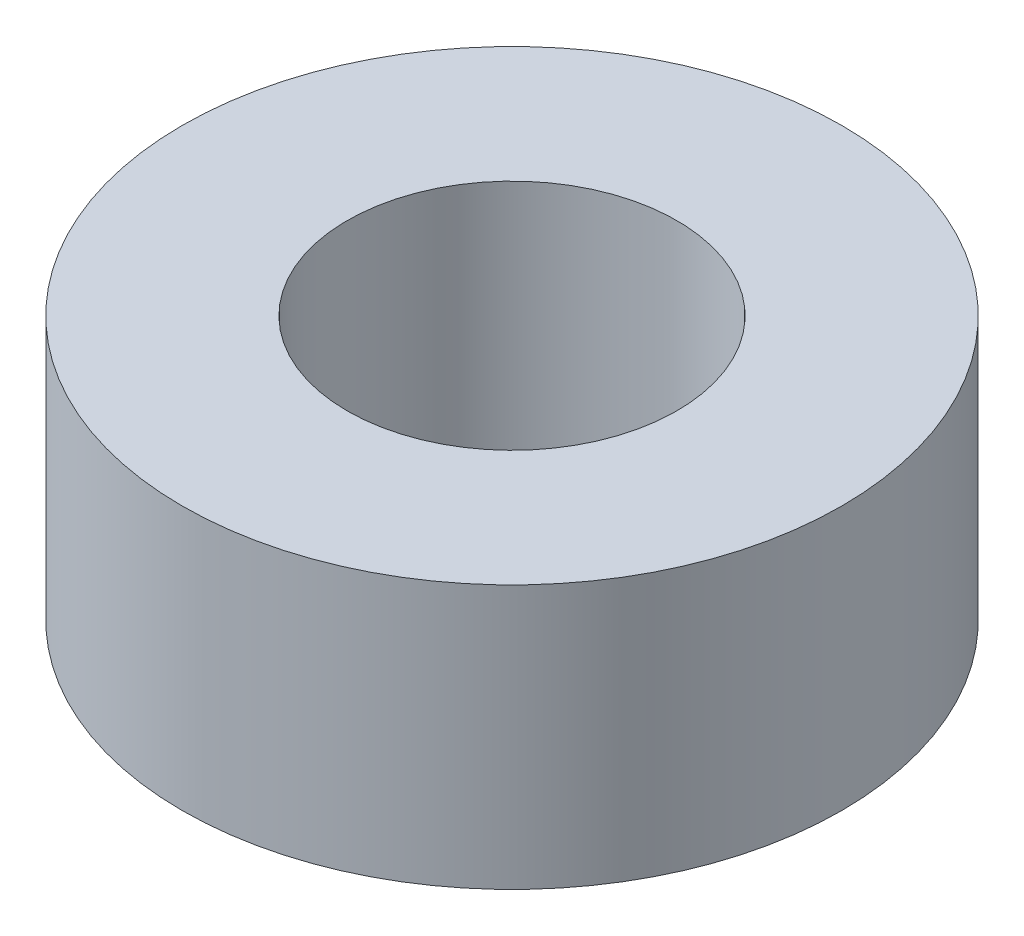
from build123d import *

# Parameters (mm, degrees)
SKETCH1_R           = 5
SKETCH1_R_2         = 2.5
BOSS_EXTRUDE1_DEPTH = 4


with BuildPart() as part:
    # Sketch1 → Boss-Extrude1 (new body)
    with BuildSketch(Plane(origin=(0, 0, 0), x_dir=(1, 0, 0), z_dir=(0, 1, 0))):
        Circle(SKETCH1_R)
        Circle(SKETCH1_R_2, mode=Mode.SUBTRACT)
    extrude(amount=BOSS_EXTRUDE1_DEPTH)


solid = part.part
